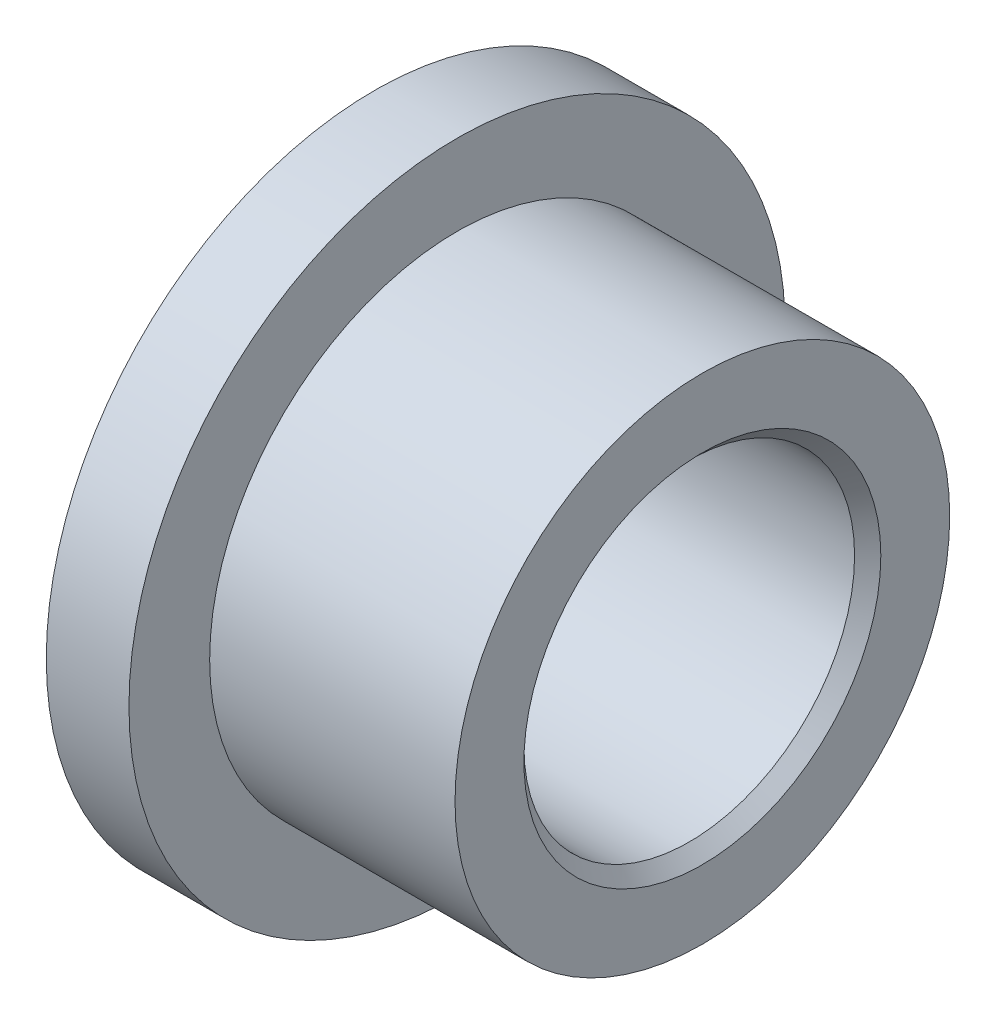
from build123d import *

# Parameters (mm, degrees)
SKETCH1_R           = 4.7879
SKETCH1_R_2         = 3.2004
BOSS_EXTRUDE1_DEPTH = 4.7498
SKETCH2_R           = 6.35
SKETCH2_R_2         = 3.2004
BOSS_EXTRUDE2_DEPTH = 1.6002
CHAMFER1_SIZE       = 0.254


with BuildPart() as part:
    # Sketch1 → Boss-Extrude1 (new body)
    with BuildSketch(Plane(origin=(0, 0, 0), x_dir=(0, 0, -1), z_dir=(1, 0, 0))):
        Circle(SKETCH1_R)
        Circle(SKETCH1_R_2, mode=Mode.SUBTRACT)
    extrude(amount=BOSS_EXTRUDE1_DEPTH)

    # Sketch2 → Boss-Extrude2 (add)
    with BuildSketch(Plane.ZY):
        Circle(SKETCH2_R)
        Circle(SKETCH2_R_2, mode=Mode.SUBTRACT)
    extrude(amount=BOSS_EXTRUDE2_DEPTH)

    # Chamfer1
    chamfer1_edges = [part.edges().sort_by_distance(p)[0] for p in [
        (-1.6002, 0, -3.2004),
        (4.7498, 0, 3.2004),
    ]]
    chamfer(chamfer1_edges, length=CHAMFER1_SIZE)


solid = part.part
